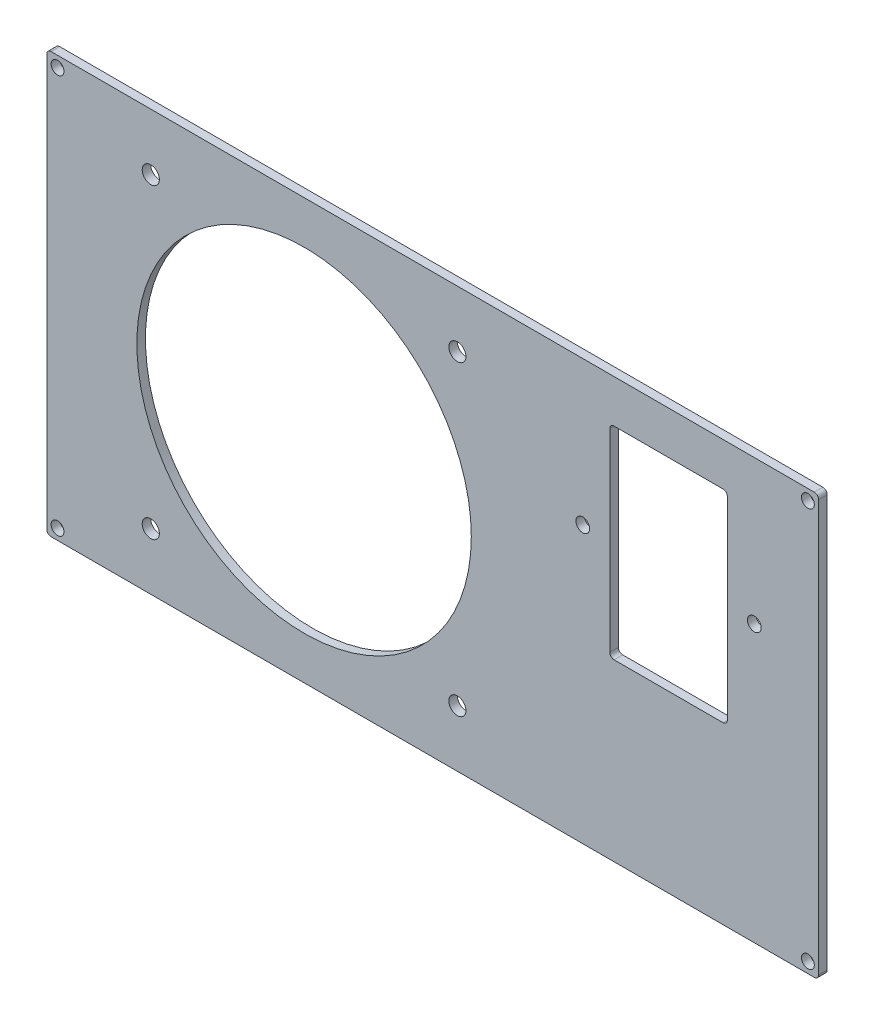
from build123d import *

# Parameters (mm, degrees)
SKETCH_1_W      = 180
SKETCH_1_H      = 98
SKETCH_1_R      = 1.5
SKETCH_1_R_2    = 39
SKETCH_1_R_3    = 2
SKETCH_1_R_4    = 1.6
SKETCH_1_W_2    = 27.4
SKETCH_1_H_2    = 47.2
EXTRUDE_1_DEPTH = 2
FILLET_1_R      = 1
FILLET_2_R      = 1


with BuildPart() as part:
    # Эскиз1 → Бобышка-Вытянуть1 (new body)
    with BuildSketch(Plane.XY):
        with Locations((90, 49)):
            Rectangle(SKETCH_1_W, SKETCH_1_H)
        with Locations((2.5, 95.5)):
            Circle(SKETCH_1_R, mode=Mode.SUBTRACT)
        with Locations((177.5, 95.5)):
            Circle(SKETCH_1_R, mode=Mode.SUBTRACT)
        with Locations((177.5, 2.5)):
            Circle(SKETCH_1_R, mode=Mode.SUBTRACT)
        with Locations((2.5, 2.5)):
            Circle(SKETCH_1_R, mode=Mode.SUBTRACT)
        with Locations((60, 49)):
            Circle(SKETCH_1_R_2, mode=Mode.SUBTRACT)
        with Locations((24.25, 84.75)):
            Circle(SKETCH_1_R_3, mode=Mode.SUBTRACT)
        with Locations((95.75, 84.75)):
            Circle(SKETCH_1_R_3, mode=Mode.SUBTRACT)
        with Locations((95.75, 13.25)):
            Circle(SKETCH_1_R_3, mode=Mode.SUBTRACT)
        with Locations((24.25, 13.25)):
            Circle(SKETCH_1_R_3, mode=Mode.SUBTRACT)
        with Locations((125, 64.4)):
            Circle(SKETCH_1_R_4, mode=Mode.SUBTRACT)
        with Locations((165, 64.4)):
            Circle(SKETCH_1_R_4, mode=Mode.SUBTRACT)
        with Locations((145, 64.4)):
            Rectangle(SKETCH_1_W_2, SKETCH_1_H_2, mode=Mode.SUBTRACT)
    extrude(amount=EXTRUDE_1_DEPTH)

    # Скругление1
    fillet_1_edges = [part.edges().sort_by_distance(p)[0] for p in [
        (0, 98, 1),
        (180, 98, 1),
        (180, 0, 1),
        (0, 0, 1),
    ]]
    fillet(fillet_1_edges, radius=FILLET_1_R)

    # Скругление2
    fillet_2_edges = [part.edges().sort_by_distance(p)[0] for p in [
        (158.7, 40.8, 1),
        (158.7, 88, 1),
        (131.3, 88, 1),
        (131.3, 40.8, 1),
    ]]
    fillet(fillet_2_edges, radius=FILLET_2_R)


solid = part.part
